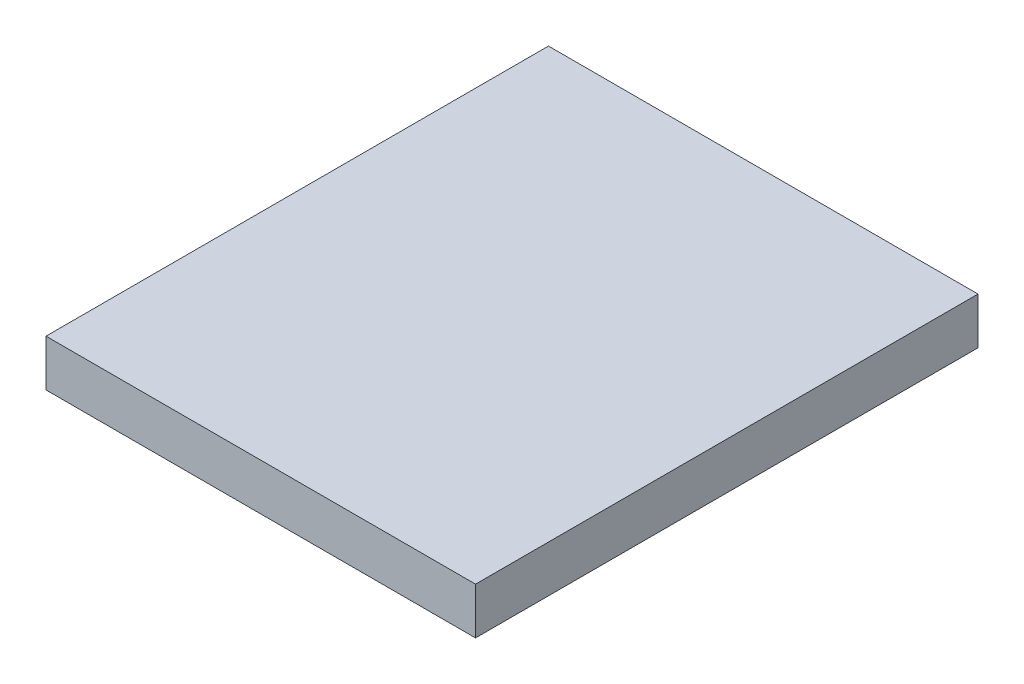
from build123d import *

# Parameters (mm, degrees)
SKETCH1_W           = 53
SKETCH1_H           = 62
BOSS_EXTRUDE1_DEPTH = 5.75


with BuildPart() as part:
    # Sketch1 → Boss-Extrude1 (new body)
    with BuildSketch(Plane(origin=(0, 0, 0), x_dir=(1, 0, 0), z_dir=(0, 1, 0))):
        Rectangle(SKETCH1_W, SKETCH1_H)
    extrude(amount=BOSS_EXTRUDE1_DEPTH)


solid = part.part
